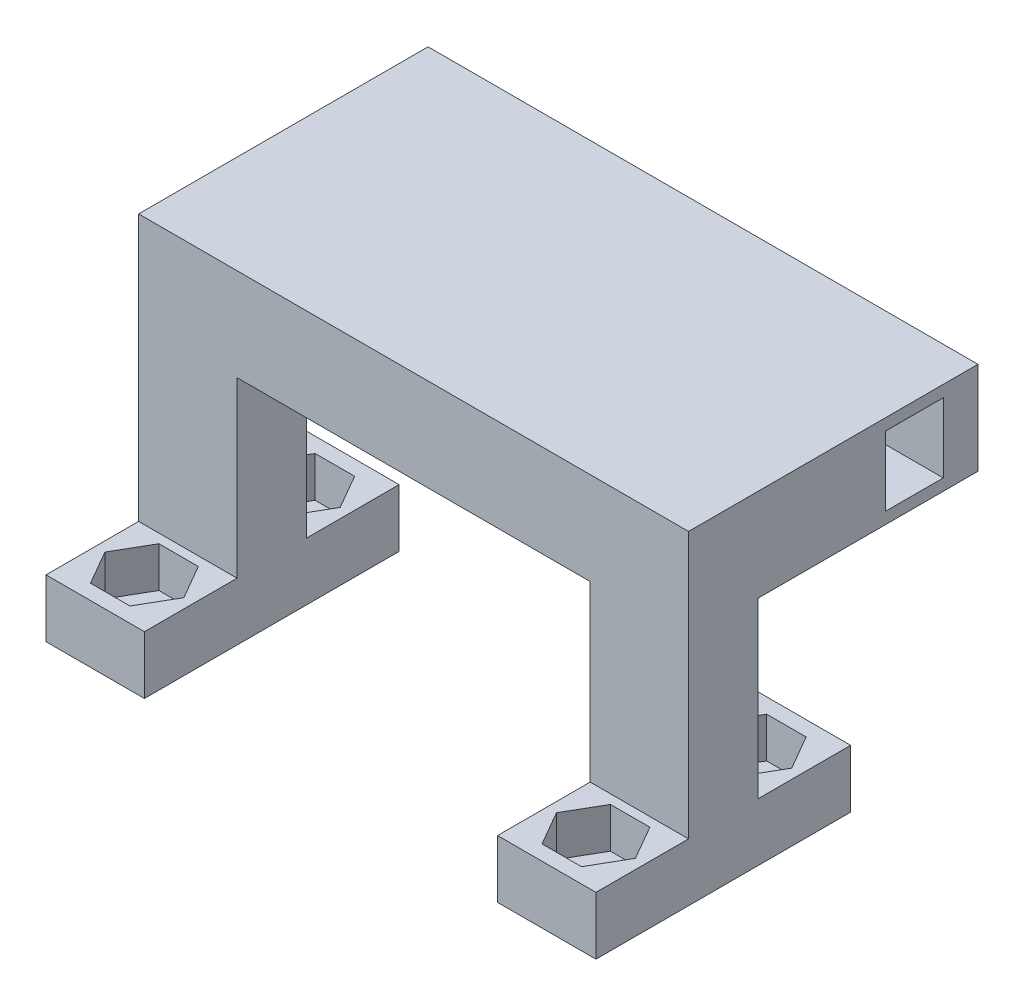
from build123d import *

# Parameters (mm, degrees)
SKETCH1_W           = 8.5
SKETCH1_H           = 22
BOSS_EXTRUDE1_DEPTH = 5
CUT_EXTRUDE1_DEPTH  = 3.5
SKETCH3_R           = 1.5
CUT_EXTRUDE2_DEPTH  = 1.5
SKETCH4_W           = 8.5
SKETCH4_H           = 6
BOSS_EXTRUDE2_DEPTH = 23
SKETCH7_W           = 8.5
SKETCH7_H           = 22
BOSS_EXTRUDE4_DEPTH = 5
CUT_EXTRUDE3_DEPTH  = 3.5
SKETCH9_R           = 1.5
CUT_EXTRUDE4_DEPTH  = 3.5
SKETCH10_W          = 8.5
SKETCH10_H          = 6
BOSS_EXTRUDE5_DEPTH = 23
SKETCH6_W           = 6
SKETCH6_H           = 8
BOSS_EXTRUDE6_DEPTH = 30.5
SKETCH11_W          = 47.5
SKETCH11_H          = 8
BOSS_EXTRUDE7_DEPTH = 13.5
SKETCH12_W          = 47.5
SKETCH12_H          = 8
BOSS_EXTRUDE8_DEPTH = 5.5
SKETCH13_W          = 5
SKETCH13_H          = 6
CUT_EXTRUDE5_DEPTH  = 15
SKETCH14_W          = 5
SKETCH14_H          = 6
CUT_EXTRUDE6_DEPTH  = 4
SKETCH15_W          = 5
SKETCH15_H          = 6
CUT_EXTRUDE7_DEPTH  = 15
SKETCH16_W          = 5
SKETCH16_H          = 6
CUT_EXTRUDE8_DEPTH  = 4


with BuildPart() as part:
    # Sketch1 → Boss-Extrude1 (new body)
    with BuildSketch(Plane(origin=(0, 0, 0), x_dir=(1, 0, 0), z_dir=(0, 1, 0))):
        Rectangle(SKETCH1_W, SKETCH1_H)
    extrude(amount=BOSS_EXTRUDE1_DEPTH)

    # Sketch2 → Cut-Extrude1 (cut)
    with BuildSketch(Plane(origin=(0, 5, 0), x_dir=(1, 0, 0), z_dir=(0, 1, 0))):
        Polygon((-1.705, 9.703146627), (-3.41, 6.75), (-1.705, 3.796853373), (1.705, 3.796853373), (3.41, 6.75), (1.705, 9.703146627), align=None)
        Polygon((1.705, -9.703146627), (-1.705, -9.703146627), (-3.41, -6.75), (-1.705, -3.796853373), (1.705, -3.796853373), (3.41, -6.75), align=None)
    extrude(amount=-CUT_EXTRUDE1_DEPTH, mode=Mode.SUBTRACT)

    # Sketch3 → Cut-Extrude2 (cut)
    with BuildSketch(Plane(origin=(0, 1.5, 0), x_dir=(1, 0, 0), z_dir=(0, 1, 0))):
        with Locations((0, 6.75)):
            Circle(SKETCH3_R)
        with Locations((0, -6.75)):
            Circle(SKETCH3_R)
        with Locations((39, 6.75)):
            Circle(SKETCH3_R)
        with Locations((39, -6.75)):
            Circle(SKETCH3_R)
    extrude(amount=-CUT_EXTRUDE2_DEPTH, mode=Mode.SUBTRACT)

    # Sketch4 → Boss-Extrude2 (add)
    with BuildSketch(Plane(origin=(0, 5, 0), x_dir=(1, 0, 0), z_dir=(0, 1, 0))):
        Rectangle(SKETCH4_W, SKETCH4_H)
    extrude(amount=BOSS_EXTRUDE2_DEPTH)



with BuildPart() as body_2:
    # Sketch7 → Boss-Extrude4 (new body)
    with BuildSketch(Plane(origin=(0, 0, 0), x_dir=(1, 0, 0), z_dir=(0, 1, 0))):
        with Locations((39, 0)):
            Rectangle(SKETCH7_W, SKETCH7_H)
    extrude(amount=BOSS_EXTRUDE4_DEPTH)

    # Sketch8 → Cut-Extrude3 (cut)
    with BuildSketch(Plane(origin=(0, 5, 0), x_dir=(1, 0, 0), z_dir=(0, 1, 0))):
        Polygon((40.705, 9.703146627), (37.295, 9.703146627), (35.59, 6.75), (37.295, 3.796853373), (40.705, 3.796853373), (42.41, 6.75), align=None)
        Polygon((40.705, -3.796853373), (37.295, -3.796853373), (35.59, -6.75), (37.295, -9.703146627), (40.705, -9.703146627), (42.41, -6.75), align=None)
    extrude(amount=-CUT_EXTRUDE3_DEPTH, mode=Mode.SUBTRACT)

    # Sketch9 → Cut-Extrude4 (cut)
    with BuildSketch(Plane(origin=(0, 1.5, 0), x_dir=(1, 0, 0), z_dir=(0, 1, 0))):
        with Locations((39, 6.75)):
            Circle(SKETCH9_R)
        with Locations((39, -6.75)):
            Circle(SKETCH9_R)
    extrude(amount=-CUT_EXTRUDE4_DEPTH, mode=Mode.SUBTRACT)

    # Sketch10 → Boss-Extrude5 (add)
    with BuildSketch(Plane(origin=(0, 5, 0), x_dir=(1, 0, 0), z_dir=(0, 1, 0))):
        with Locations((39, 0)):
            Rectangle(SKETCH10_W, SKETCH10_H)
    extrude(amount=BOSS_EXTRUDE5_DEPTH)


with BuildPart() as part_1:
    add(part.part)

    add(body_2.part)  # Boss-Extrude6 merges body 2
    # Sketch6 → Boss-Extrude6 (add)
    with BuildSketch(Plane(origin=(4.25, 0, 0), x_dir=(0, 0, -1), z_dir=(1, 0, 0))):
        with Locations((0, 24)):
            Rectangle(SKETCH6_W, SKETCH6_H)
    extrude(amount=BOSS_EXTRUDE6_DEPTH)

    # Sketch11 → Boss-Extrude7 (add)
    with BuildSketch(Plane(origin=(0, 0, -3), x_dir=(-1, 0, 0), z_dir=(0, 0, -1))):
        with Locations((-19.5, 24)):
            Rectangle(SKETCH11_W, SKETCH11_H)
    extrude(amount=BOSS_EXTRUDE7_DEPTH)

    # Sketch12 → Boss-Extrude8 (add)
    with BuildSketch(Plane(origin=(0, 0, -16.5), x_dir=(-1, 0, 0), z_dir=(0, 0, -1))):
        with Locations((-19.5, 24)):
            Rectangle(SKETCH12_W, SKETCH12_H)
    extrude(amount=BOSS_EXTRUDE8_DEPTH)

    # Sketch13 → Cut-Extrude5 (cut)
    with BuildSketch(Plane.ZY.offset(4.25)):
        with Locations((-16.5, 24)):
            Rectangle(SKETCH13_W, SKETCH13_H)
    extrude(amount=-CUT_EXTRUDE5_DEPTH, mode=Mode.SUBTRACT)

    # Sketch14 → Cut-Extrude6 (cut)
    with BuildSketch(Plane(origin=(0, 0, -22), x_dir=(-1, 0, 0), z_dir=(0, 0, -1))):
        with Locations((-8.25, 24)):
            Rectangle(SKETCH14_W, SKETCH14_H)
    extrude(amount=-CUT_EXTRUDE6_DEPTH, mode=Mode.SUBTRACT)

    # Sketch15 → Cut-Extrude7 (cut)
    with BuildSketch(Plane(origin=(43.25, 0, 0), x_dir=(0, 0, -1), z_dir=(1, 0, 0))):
        with Locations((16.5, 24)):
            Rectangle(SKETCH15_W, SKETCH15_H)
    extrude(amount=-CUT_EXTRUDE7_DEPTH, mode=Mode.SUBTRACT)

    # Sketch16 → Cut-Extrude8 (cut)
    with BuildSketch(Plane(origin=(0, 0, -22), x_dir=(-1, 0, 0), z_dir=(0, 0, -1))):
        with Locations((-30.75, 24)):
            Rectangle(SKETCH16_W, SKETCH16_H)
    extrude(amount=-CUT_EXTRUDE8_DEPTH, mode=Mode.SUBTRACT)


solid = part_1.part
